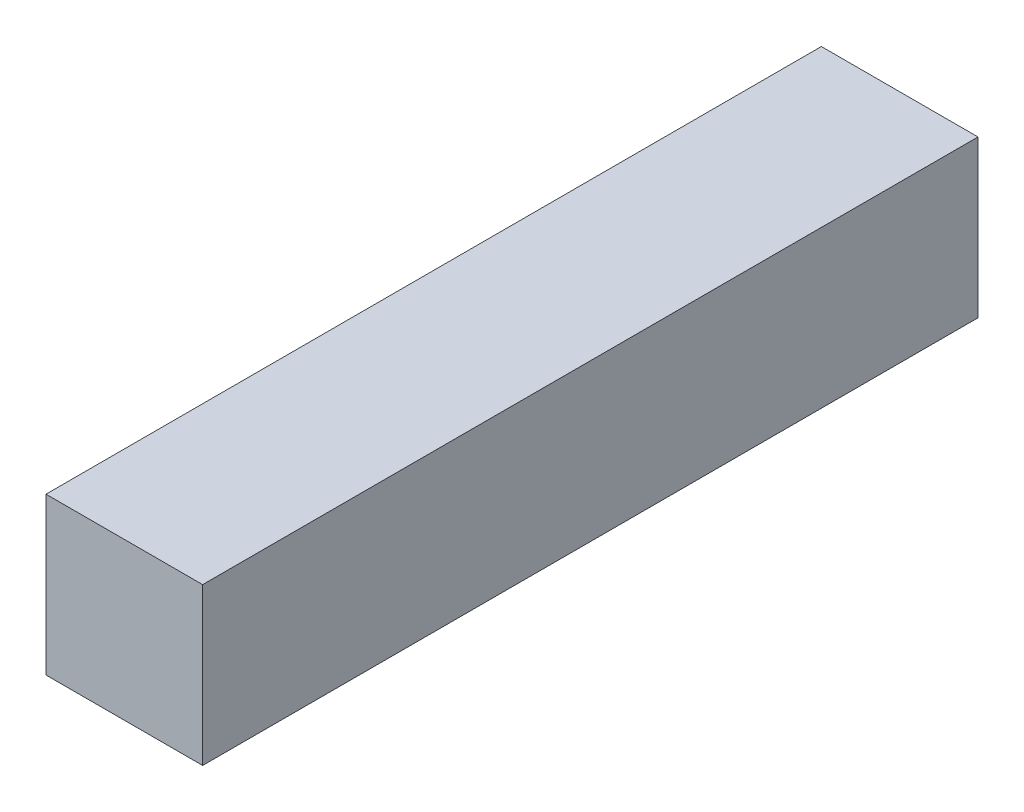
from build123d import *

# Parameters (mm, degrees)
SKETCH1_W           = 2
SKETCH1_H           = 9.9
BOSS_EXTRUDE1_DEPTH = 2


with BuildPart() as part:
    # Sketch1 → Boss-Extrude1 (new body)
    with BuildSketch(Plane(origin=(0, 0, 0), x_dir=(1, 0, 0), z_dir=(0, 1, 0))):
        Rectangle(SKETCH1_W, SKETCH1_H)
    extrude(amount=BOSS_EXTRUDE1_DEPTH)


solid = part.part
